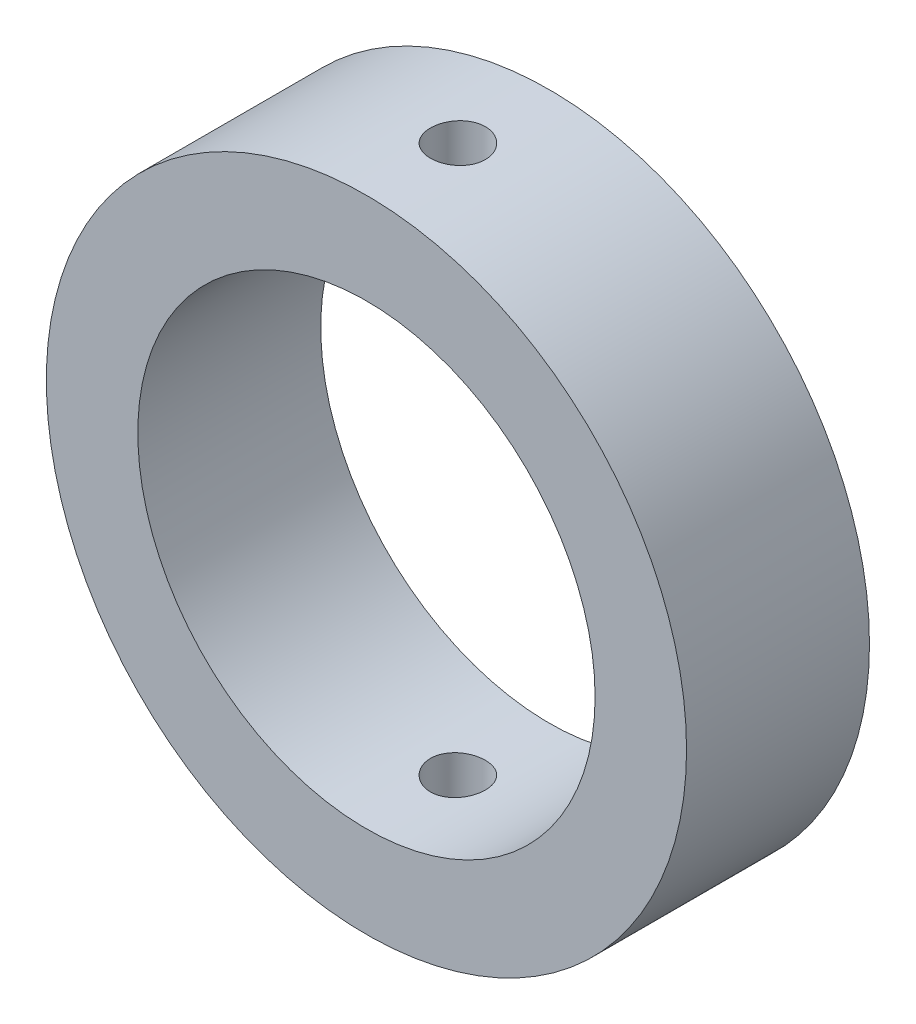
from build123d import *

# Parameters (mm, degrees)
SKETCH2_R               = 350
SKETCH2_R_2             = 250
BOSS_EXTRUDE1_DEPTH     = 200
SKETCH3_R               = 30
CUT_EXTRUDE1_DEPTH      = 351
CUT_EXTRUDE1_DEPTH_BACK = 351


with BuildPart() as part:
    # Sketch2 → Boss-Extrude1 (new body)
    with BuildSketch(Plane.XY):
        Circle(SKETCH2_R)
        Circle(SKETCH2_R_2, mode=Mode.SUBTRACT)
    extrude(amount=BOSS_EXTRUDE1_DEPTH)

    # Sketch3 → Cut-Extrude1 (cut, two sides)
    with BuildSketch(Plane(origin=(0, 0, 0), x_dir=(1, 0, 0), z_dir=(0, 1, 0))) as cut_extrude1_sk:
        with Locations((0, -100)):
            Circle(SKETCH3_R)
    extrude(amount=CUT_EXTRUDE1_DEPTH, mode=Mode.SUBTRACT)
    extrude(cut_extrude1_sk.sketch, amount=-CUT_EXTRUDE1_DEPTH_BACK, mode=Mode.SUBTRACT)


solid = part.part
